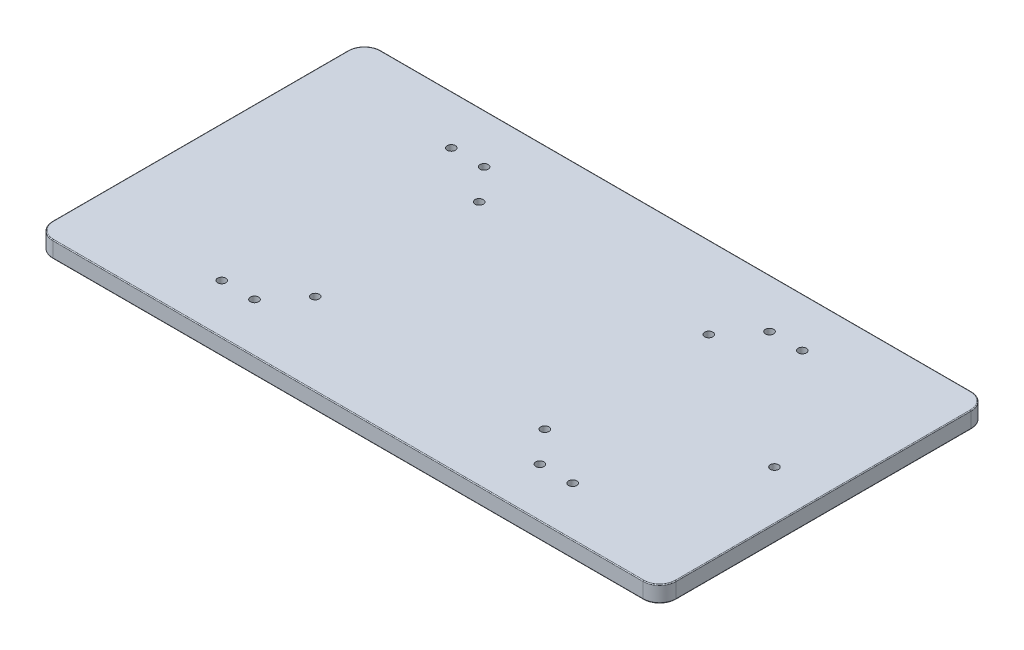
from build123d import *

# Parameters (mm, degrees)
SKETCH1_W           = 190
SKETCH1_H           = 100
SKETCH1_R           = 1.25
BOSS_EXTRUDE1_DEPTH = 5
FILLET1_R           = 5
FILLET2_R           = 0.25
BOSS_EXTRUDE2_DEPTH = 5


with BuildPart() as part:
    # Sketch1 → Boss-Extrude1 (new body)
    with BuildSketch(Plane(origin=(0, 0, 0), x_dir=(1, 0, 0), z_dir=(0, 1, 0))):
        Rectangle(SKETCH1_W, SKETCH1_H)
        with Locations((-53.5, -35)):
            Circle(SKETCH1_R, mode=Mode.SUBTRACT)
        with Locations((-43.5, -35)):
            Circle(SKETCH1_R, mode=Mode.SUBTRACT)
        with Locations((43.5, -35)):
            Circle(SKETCH1_R, mode=Mode.SUBTRACT)
        with Locations((53.5, -35)):
            Circle(SKETCH1_R, mode=Mode.SUBTRACT)
        with BuildLine():
            ThreePointArc((-35, 23.75), (-35.883883476, 25.883883476), (-33.75, 25))
            Line((-33.75, 25), (33.75, 25))
            ThreePointArc((33.75, 25), (35, 26.25), (36.25, 25))
            ThreePointArc((36.25, 25), (35.883883476, 24.116116524), (35, 23.75))
            Line((35, 23.75), (35, -23.75))
            ThreePointArc((35, -23.75), (35.883883476, -24.116116524), (36.25, -25))
            ThreePointArc((36.25, -25), (35, -26.25), (33.75, -25))
            Line((33.75, -25), (-33.75, -25))
            ThreePointArc((-33.75, -25), (-35.883883476, -25.883883476), (-35, -23.75))
            Line((-35, -23.75), (-35, 23.75))
        make_face(mode=Mode.SUBTRACT)
        with Locations((-53.5, 35)):
            Circle(SKETCH1_R, mode=Mode.SUBTRACT)
        with Locations((-43.5, 35)):
            Circle(SKETCH1_R, mode=Mode.SUBTRACT)
        with Locations((80, 0)):
            Circle(SKETCH1_R, mode=Mode.SUBTRACT)
        with Locations((43.5, 35)):
            Circle(SKETCH1_R, mode=Mode.SUBTRACT)
        with Locations((53.5, 35)):
            Circle(SKETCH1_R, mode=Mode.SUBTRACT)
    extrude(amount=BOSS_EXTRUDE1_DEPTH)

    # Fillet1
    fillet1_edges = [part.edges().sort_by_distance(p)[0] for p in [
        (95, 2.5, -50),
        (95, 2.5, 50),
        (-95, 2.5, -50),
        (-95, 2.5, 50),
    ]]
    fillet(fillet1_edges, radius=FILLET1_R)

    # Fillet2
    fillet2_edges = [part.edges().sort_by_distance(p)[0] for p in [
        (93.535533906, 0, 48.535533906),
        (95, 0, 0),
        (93.535533906, 0, -48.535533906),
        (0, 0, -50),
        (-93.535533906, 0, -48.535533906),
        (-95, 0, 0),
        (-93.535533906, 0, 48.535533906),
        (93.535533906, 5, 48.535533906),
        (95, 5, 0),
        (93.535533906, 5, -48.535533906),
        (0, 5, -50),
        (-93.535533906, 5, -48.535533906),
        (-95, 5, 0),
        (-93.535533906, 5, 48.535533906),
        (0, 0, 50),
        (0, 5, 50),
    ]]
    fillet(fillet2_edges, radius=FILLET2_R)

    # Sketch1_4 → Boss-Extrude2 (add)
    with BuildSketch(Plane(origin=(0, 0, 0), x_dir=(1, 0, 0), z_dir=(0, 1, 0))):
        with BuildLine():
            Line((33.75, 25), (-33.75, 25))
            ThreePointArc((-33.75, 25), (-34.116116524, 24.116116524), (-35, 23.75))
            Line((-35, 23.75), (-35, -23.75))
            ThreePointArc((-35, -23.75), (-34.116116524, -24.116116524), (-33.75, -25))
            Line((-33.75, -25), (33.75, -25))
            ThreePointArc((33.75, -25), (34.116116524, -24.116116524), (35, -23.75))
            Line((35, -23.75), (35, 23.75))
            ThreePointArc((35, 23.75), (34.116116524, 24.116116524), (33.75, 25))
        make_face()
    extrude(amount=BOSS_EXTRUDE2_DEPTH)


solid = part.part
